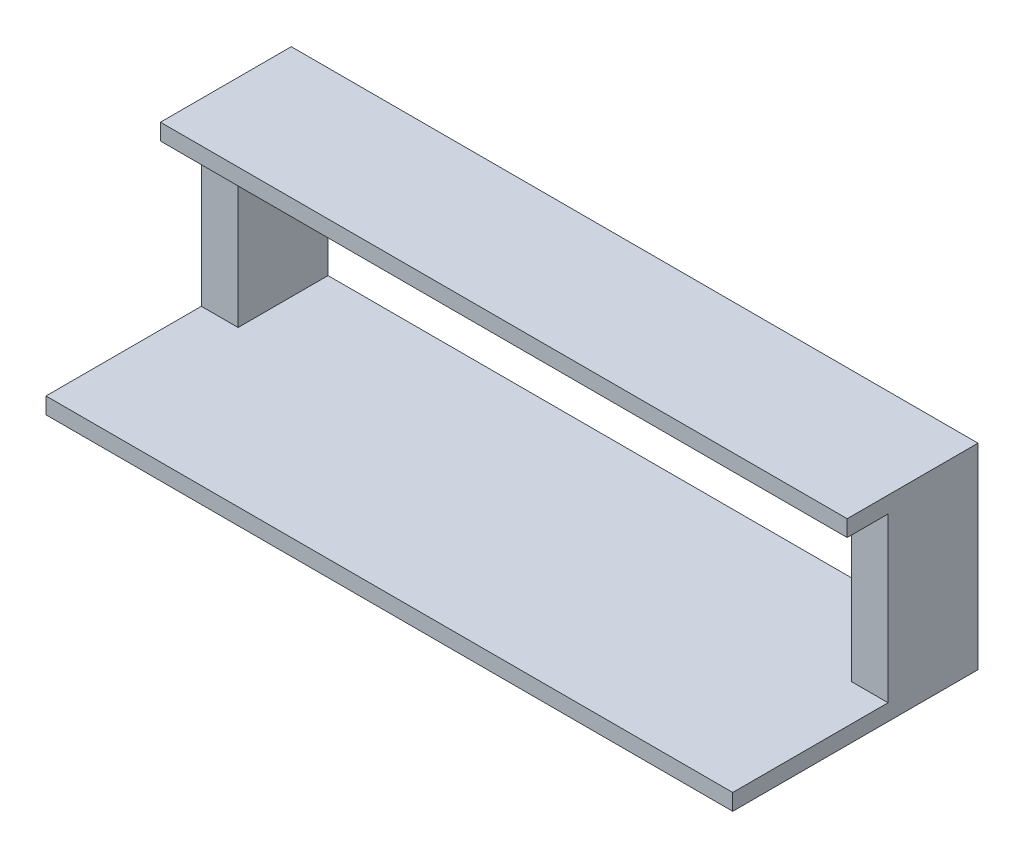
from build123d import *

# Parameters (mm, degrees)
SKETCH1_W           = 2133.6
SKETCH1_H           = 762
BOSS_EXTRUDE1_DEPTH = 50.8
SKETCH3_W           = 114.3
SKETCH3_H           = 279.4
BOSS_EXTRUDE2_DEPTH = 508
SKETCH4_W           = 2133.6
SKETCH4_H           = 279.4
BOSS_EXTRUDE3_DEPTH = 50.8
SKETCH5_W           = 2133.6
SKETCH5_H           = 50.8
BOSS_EXTRUDE4_DEPTH = 127


with BuildPart() as part:
    # Sketch1 → Boss-Extrude1 (new body)
    with BuildSketch(Plane(origin=(0, 0, 0), x_dir=(1, 0, 0), z_dir=(0, 1, 0))):
        Rectangle(SKETCH1_W, SKETCH1_H)
    extrude(amount=BOSS_EXTRUDE1_DEPTH)

    # Sketch3 → Boss-Extrude2 (add)
    with BuildSketch(Plane(origin=(0, 50.8, 0), x_dir=(1, 0, 0), z_dir=(0, 1, 0))):
        with Locations((-1009.65, 241.3)):
            Rectangle(SKETCH3_W, SKETCH3_H)
        with Locations((1009.65, 241.3)):
            Rectangle(SKETCH3_W, SKETCH3_H)
    extrude(amount=BOSS_EXTRUDE2_DEPTH)

    # Sketch4 → Boss-Extrude3 (add)
    with BuildSketch(Plane(origin=(0, 558.8, 0), x_dir=(1, 0, 0), z_dir=(0, 1, 0))):
        with Locations((0, 241.3)):
            Rectangle(SKETCH4_W, SKETCH4_H)
    extrude(amount=BOSS_EXTRUDE3_DEPTH)

    # Sketch5 → Boss-Extrude4 (add)
    with BuildSketch(Plane.XY.offset(-101.6)):
        with Locations((0, 584.2)):
            Rectangle(SKETCH5_W, SKETCH5_H)
    extrude(amount=BOSS_EXTRUDE4_DEPTH)


solid = part.part
